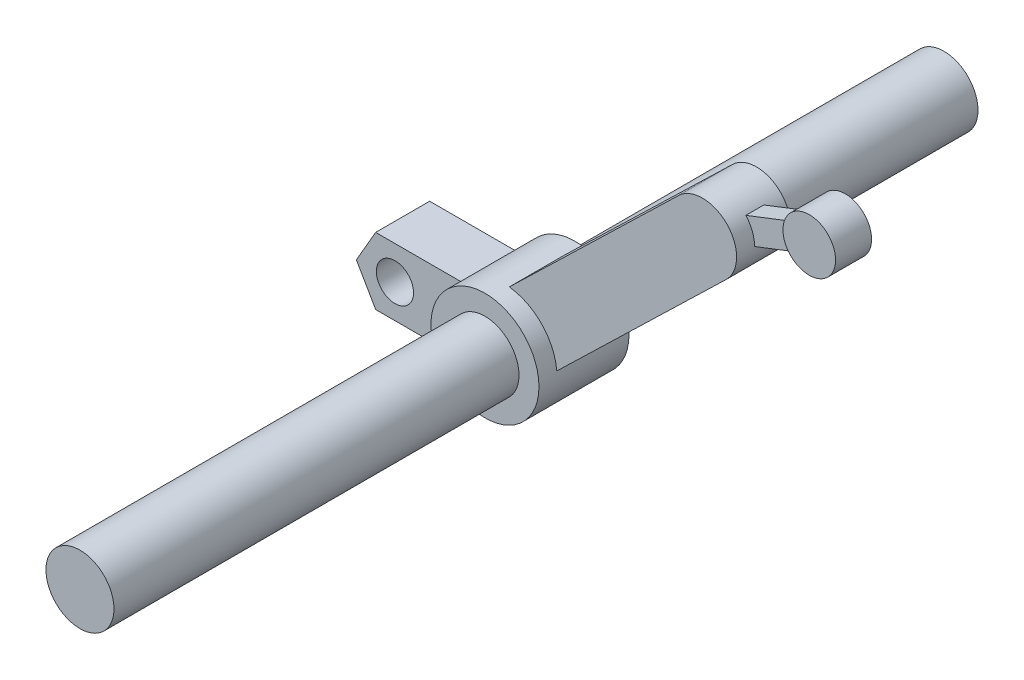
from build123d import *

# Parameters (mm, degrees)
IZIM1_R                     = 1.89
Y_KSEKLIK_EKSTR_ZYON1_DEPTH = 48
IZIM2_R                     = 3
Y_KSEKLIK_EKSTR_ZYON2_DEPTH = 2.5
Y_KSEKLIK_EKSTR_ZYON3_DEPTH = 1.5
Y_KSEKLIK_EKSTR_ZYON7_DEPTH = 1.5
Y_KSEKLIK_EKSTR_ZYON8_DEPTH = 0.5
IZIM6_4_R                   = 1.461469514
Y_KSEKLIK_EKSTR_ZYON9_DEPTH = 1
IZIM8_R                     = 1.032330659
KES_EKSTR_ZYON1_DEPTH       = 4


with BuildPart() as part:
    # Çizim1 → Yükseklik-Ekstrüzyon1 (new body)
    with BuildSketch(Plane.XY):
        Circle(IZIM1_R)
    extrude(amount=Y_KSEKLIK_EKSTR_ZYON1_DEPTH)

    # Çizim2 → Yükseklik-Ekstrüzyon2 (add, symmetric)
    with BuildSketch(Plane.XY.offset(23)):
        Circle(IZIM2_R)
    extrude(amount=Y_KSEKLIK_EKSTR_ZYON2_DEPTH, both=True)

    # Çizim2<3> → Yükseklik-Ekstrüzyon3 (add, symmetric)
    with BuildSketch(Plane.XY.offset(23)):
        Polygon((0, -1.824067041), (0, 1.89), (-7.072158803, 1.89), (-8.144317606, 0.03296648), (-7.072158803, -1.824067041), align=None)
    extrude(amount=Y_KSEKLIK_EKSTR_ZYON3_DEPTH, both=True)

    # Çizim6 → Yükseklik-Ekstrüzyon7 (add, symmetric)
    with BuildSketch(Plane.XY.offset(23)):
        with BuildLine():
            Line((9.765618481, 12.085389192), (-1.318138223, 1.362498594))
            ThreePointArc((-1.318138223, 1.362498594), (-1.362498594, -1.318138223), (1.318138223, -1.362498594))
            Line((1.318138223, -1.362498594), (12.401894927, 9.360392003))
            ThreePointArc((12.401894927, 9.360392003), (12.446255298, 12.04102882), (9.765618481, 12.085389192))
        make_face()
    extrude(amount=Y_KSEKLIK_EKSTR_ZYON7_DEPTH, both=True)

    # Çizim6<3> → Yükseklik-Ekstrüzyon8 (add, symmetric)
    with BuildSketch(Plane.XY.offset(23)):
        with BuildLine():
            Line((10.840169306, 11.350935213), (16.272383955, 13.457822202))
            ThreePointArc((16.272383955, 13.457822202), (17.144015968, 13.073364985), (16.75955875, 12.201732972))
            Line((16.75955875, 12.201732972), (11.327344102, 10.094845982))
            ThreePointArc((11.327344102, 10.094845982), (10.455712089, 10.4793032), (10.840169306, 11.350935213))
        make_face()
    extrude(amount=Y_KSEKLIK_EKSTR_ZYON8_DEPTH, both=True)

    # Çizim6<4> → Yükseklik-Ekstrüzyon9 (add, symmetric)
    with BuildSketch(Plane.XY.offset(23)):
        with Locations((16.515971352, 12.829777587)):
            Circle(IZIM6_4_R)
    extrude(amount=Y_KSEKLIK_EKSTR_ZYON9_DEPTH, both=True)

    # Çizim8 → Kes-Ekstrüzyon1 (cut)
    with BuildSketch(Plane.XY.offset(24.5)):
        with Locations((-6, 0.03296648)):
            Circle(IZIM8_R)
    extrude(amount=-KES_EKSTR_ZYON1_DEPTH, mode=Mode.SUBTRACT)


solid = part.part
